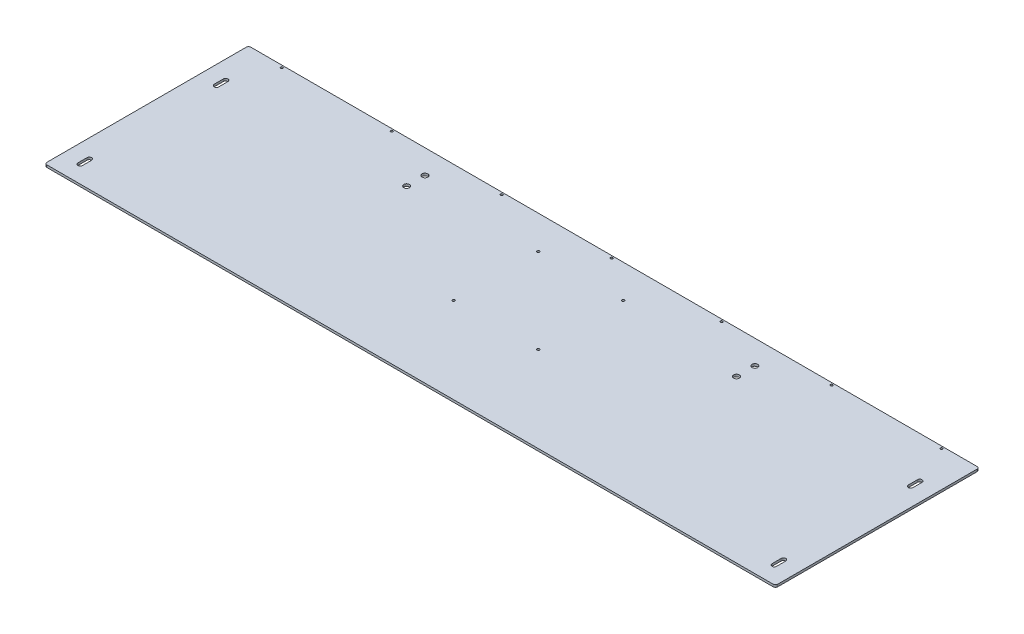
from build123d import *

# Parameters (mm, degrees)
SKETCH1_R           = 7.9375
SKETCH1_R_2         = 3.3782
SKETCH1_R_3         = 3.175
BOSS_EXTRUDE1_DEPTH = 6.35


with BuildPart() as part:
    # Sketch1 → Boss-Extrude1 (new body)
    with BuildSketch(Plane(origin=(0, 0, 0), x_dir=(1, 0, 0), z_dir=(0, 1, 0))):
        with BuildLine():
            Line((6.35, 0), (2019.3, 0))
            ThreePointArc((2019.3, 0), (2023.790128061, 1.859871939), (2025.65, 6.35))
            Line((2025.65, 6.35), (2025.65, 558.8))
            ThreePointArc((2025.65, 558.8), (2023.790128061, 563.290128061), (2019.3, 565.15))
            Line((2019.3, 565.15), (6.35, 565.15))
            ThreePointArc((6.35, 565.15), (1.859871939, 563.290128061), (0, 558.8))
            Line((0, 558.8), (0, 6.35))
            ThreePointArc((0, 6.35), (1.859871939, 1.859871939), (6.35, 0))
        make_face()
        with Locations((555.625, 447.675)):
            Circle(SKETCH1_R, mode=Mode.SUBTRACT)
        with Locations((1470.025, 447.675)):
            Circle(SKETCH1_R, mode=Mode.SUBTRACT)
        with Locations((895.35, 473.075)):
            Circle(SKETCH1_R_2, mode=Mode.SUBTRACT)
        with Locations((1130.3, 473.075)):
            Circle(SKETCH1_R_2, mode=Mode.SUBTRACT)
        with Locations((1130.3, 238.125)):
            Circle(SKETCH1_R_2, mode=Mode.SUBTRACT)
        with Locations((895.35, 238.125)):
            Circle(SKETCH1_R_2, mode=Mode.SUBTRACT)
        with Locations((555.625, 498.475)):
            Circle(SKETCH1_R, mode=Mode.SUBTRACT)
        with Locations((1470.025, 498.475)):
            Circle(SKETCH1_R, mode=Mode.SUBTRACT)
        with Locations((1927.225, 558.8)):
            Circle(SKETCH1_R_3, mode=Mode.SUBTRACT)
        with Locations((1622.425, 558.8)):
            Circle(SKETCH1_R_3, mode=Mode.SUBTRACT)
        with Locations((1317.625, 558.8)):
            Circle(SKETCH1_R_3, mode=Mode.SUBTRACT)
        with Locations((1012.825, 558.8)):
            Circle(SKETCH1_R_3, mode=Mode.SUBTRACT)
        with Locations((708.025, 558.8)):
            Circle(SKETCH1_R_3, mode=Mode.SUBTRACT)
        with Locations((403.225, 558.8)):
            Circle(SKETCH1_R_3, mode=Mode.SUBTRACT)
        with Locations((98.425, 558.8)):
            Circle(SKETCH1_R_3, mode=Mode.SUBTRACT)
        with BuildLine():
            Line((57.15, 73.025), (57.15, 47.625))
            ThreePointArc((57.15, 47.625), (50.8, 41.275), (44.45, 47.625))
            Line((44.45, 47.625), (44.45, 73.025))
            ThreePointArc((44.45, 73.025), (50.8, 79.375), (57.15, 73.025))
        make_face(mode=Mode.SUBTRACT)
        with BuildLine():
            Line((1968.5, 73.025), (1968.5, 47.625))
            ThreePointArc((1968.5, 47.625), (1974.85, 41.275), (1981.2, 47.625))
            Line((1981.2, 47.625), (1981.2, 73.025))
            ThreePointArc((1981.2, 73.025), (1974.85, 79.375), (1968.5, 73.025))
        make_face(mode=Mode.SUBTRACT)
        with BuildLine():
            Line((44.45, 425.45), (44.45, 450.85))
            ThreePointArc((44.45, 450.85), (50.8, 457.2), (57.15, 450.85))
            Line((57.15, 450.85), (57.15, 425.45))
            ThreePointArc((57.15, 425.45), (50.8, 419.1), (44.45, 425.45))
        make_face(mode=Mode.SUBTRACT)
        with BuildLine():
            Line((1981.2, 425.45), (1981.2, 450.85))
            ThreePointArc((1981.2, 450.85), (1974.85, 457.2), (1968.5, 450.85))
            Line((1968.5, 450.85), (1968.5, 425.45))
            ThreePointArc((1968.5, 425.45), (1974.85, 419.1), (1981.2, 425.45))
        make_face(mode=Mode.SUBTRACT)
    extrude(amount=BOSS_EXTRUDE1_DEPTH)


solid = part.part
